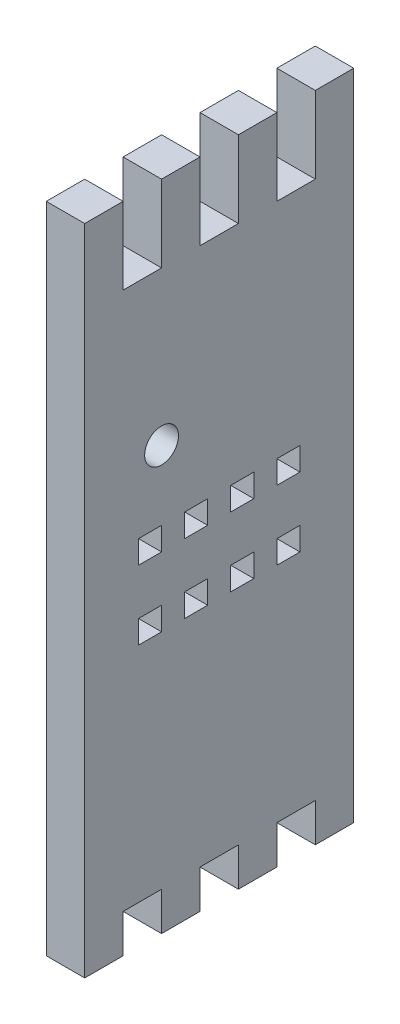
from build123d import *

# Parameters (mm, degrees)
ESQUISSE1_R             = 2.2
BOSS_EXTRU_1_DEPTH      = 5
ESQUISSE3_W             = 5
ESQUISSE3_H             = 5
BOSS_EXTRU_3_DEPTH      = 5
ESQUISSE4_W             = 3
ESQUISSE4_H             = 3
ENL_V_MAT_EXTRU_1_DEPTH = 10


with BuildPart() as part:
    # Esquisse1 → Boss.-Extru.1 (new body)
    with BuildSketch(Plane(origin=(0, 0, 0), x_dir=(0, 0, -1), z_dir=(1, 0, 0))):
        Polygon((-17.5, -40), (-12.5, -40), (-12.5, -35), (-7.5, -35), (-7.5, -40), (-2.5, -40), (-2.5, -35), (2.5, -35), (2.5, -40), (7.5, -40), (7.5, -35), (12.5, -35), (12.5, -40), (17.5, -40), (17.5, 40), (12.5, 40), (12.5, 35), (7.5, 35), (7.5, 40), (2.5, 40), (2.5, 35), (-2.5, 35), (-2.5, 40), (-7.5, 40), (-7.5, 35), (-12.5, 35), (-12.5, 40), (-17.5, 40), align=None)
        with Locations((-7.5, 15)):
            Circle(ESQUISSE1_R, mode=Mode.SUBTRACT)
    extrude(amount=BOSS_EXTRU_1_DEPTH)

    # Esquisse3 → Boss.-Extru.3 (add)
    with BuildSketch(Plane(origin=(0, 40, 0), x_dir=(1, 0, 0), z_dir=(0, 1, 0))):
        with Locations((2.5, -15)):
            Rectangle(ESQUISSE3_W, ESQUISSE3_H)
        with Locations((2.5, -5)):
            Rectangle(ESQUISSE3_W, ESQUISSE3_H)
        with Locations((2.5, 5)):
            Rectangle(ESQUISSE3_W, ESQUISSE3_H)
        with Locations((2.5, 15)):
            Rectangle(ESQUISSE3_W, ESQUISSE3_H)
    extrude(amount=BOSS_EXTRU_3_DEPTH)

    # Esquisse4 → Enlèv. mat.-Extru.1 (cut)
    with BuildSketch(Plane.ZY):
        with Locations((-3, -4.5)):
            Rectangle(ESQUISSE4_W, ESQUISSE4_H)
        with Locations((-9, -4.5)):
            Rectangle(ESQUISSE4_W, ESQUISSE4_H)
        with Locations((3, -4.5)):
            Rectangle(ESQUISSE4_W, ESQUISSE4_H)
        with Locations((9, -4.5)):
            Rectangle(ESQUISSE4_W, ESQUISSE4_H)
        with Locations((9, 4.5)):
            Rectangle(ESQUISSE4_W, ESQUISSE4_H)
        with Locations((3, 4.5)):
            Rectangle(ESQUISSE4_W, ESQUISSE4_H)
        with Locations((-3, 4.5)):
            Rectangle(ESQUISSE4_W, ESQUISSE4_H)
        with Locations((-9, 4.5)):
            Rectangle(ESQUISSE4_W, ESQUISSE4_H)
    extrude(amount=-ENL_V_MAT_EXTRU_1_DEPTH, mode=Mode.SUBTRACT)


solid = part.part
